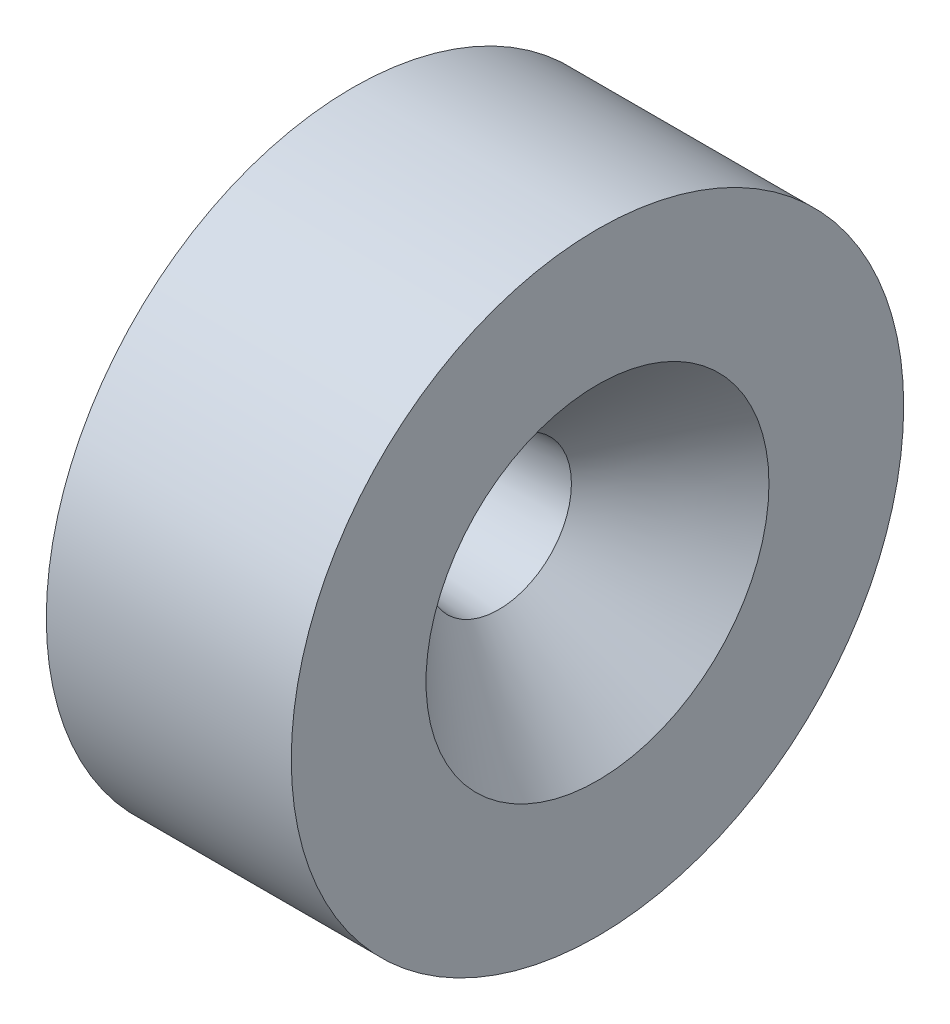
from build123d import *

# Parameters (mm, degrees)
SKETCH_1_R      = 5
EXTRUDE_1_DEPTH = 4
CHAMFER_1_SIZE  = 1.5
CHAMFER_1_SIZE2 = 1.616714541


with BuildPart() as part:
    # 草图1 → 凸台-拉伸1 (new body)
    with BuildSketch(Plane(origin=(0, 0, 0), x_dir=(0, 0, -1), z_dir=(1, 0, 0))):
        with Locations((-9.325362428, -21.699923803)):
            Circle(SKETCH_1_R)
    extrude(amount=EXTRUDE_1_DEPTH)

    # 切除-拉伸1 cone 1 section (through the dimple's axis) → 切除-拉伸1 (revolve, cut)
    with BuildSketch(Plane(origin=(4, -21.699923803, 9.325362428), x_dir=(0, 0, -1), z_dir=(0, 1, 0))):
        Polygon((0, 0), (1.3, 0), (0, 18.590866134), align=None)
    revolve(axis=Axis((4, -21.699923803, 9.325362428), (-1, 0, 0)), mode=Mode.SUBTRACT)

    # 倒角1
    chamfer_1_edges = [part.edges().sort_by_distance(p)[0] for p in [
        (4, -21.699923803, 10.625362428),
    ]]
    chamfer_1_side = [part.faces().sort_by_distance(p)[0] for p in [
        (4, -21.699923803, 14.183941072),
    ]]
    chamfer(chamfer_1_edges, length=CHAMFER_1_SIZE, length2=CHAMFER_1_SIZE2, reference=chamfer_1_side[0])


solid = part.part
